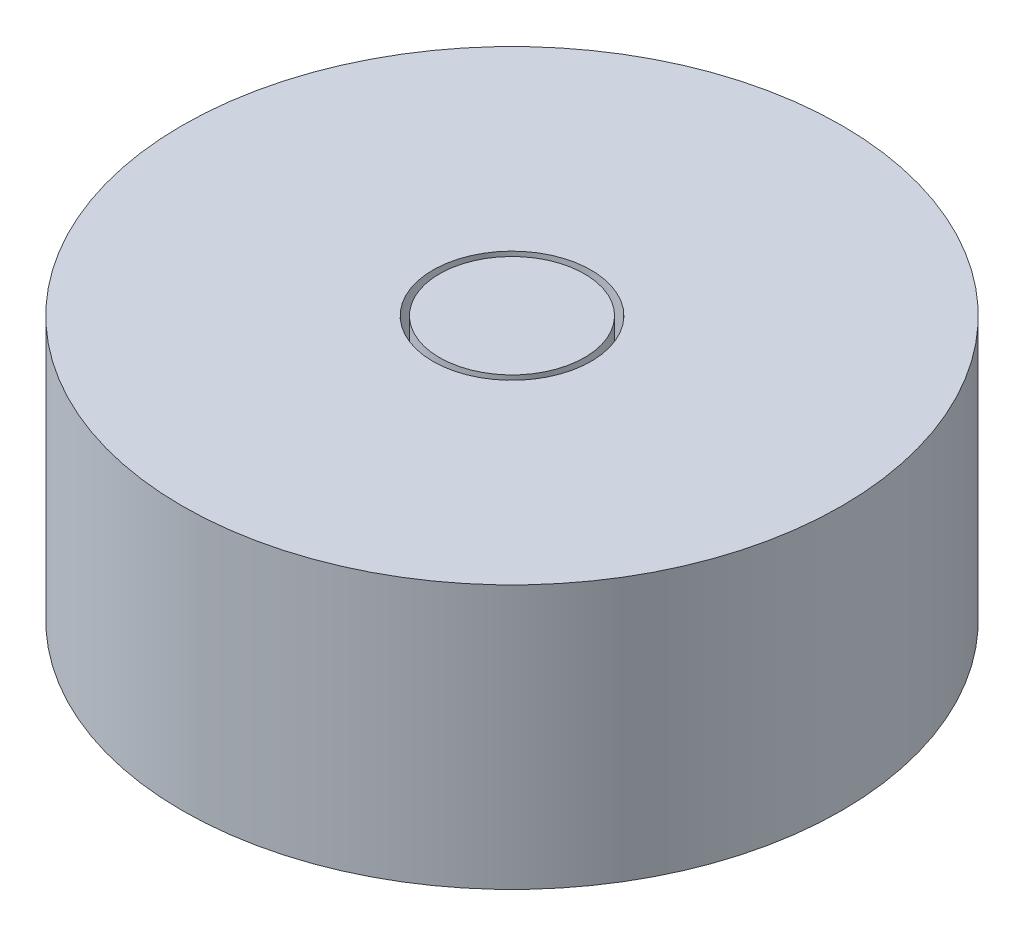
from build123d import *

# Parameters (mm, degrees)
SKETCH1_R      = 6.25
EXTRUDE1_DEPTH = 5
SKETCH2_R      = 1.5
SKETCH2_R_2    = 1.375
EXTRUDE2_DEPTH = 1


with BuildPart() as part:
    # Sketch1 → Extrude1 (new body)
    with BuildSketch(Plane(origin=(0, 0, 0), x_dir=(1, 0, 0), z_dir=(0, 1, 0))):
        with Locations(Location((0, 0, 0), (0, 0, 270))):  # turned: the seam where the file's is
            Circle(SKETCH1_R)
    extrude(amount=EXTRUDE1_DEPTH)

    # Sketch2 → Extrude2 (cut)
    with BuildSketch(Plane(origin=(0, 5, 0), x_dir=(1, 0, 0), z_dir=(0, 1, 0))):
        with Locations(Location((0, 0, 0), (0, 0, 270))):  # turned: the seam where the file's is
            Circle(SKETCH2_R)
        with Locations(Location((0, 0, 0), (0, 0, 270))):  # turned: the seam where the file's is
            Circle(SKETCH2_R_2, mode=Mode.SUBTRACT)
    extrude(amount=-EXTRUDE2_DEPTH, mode=Mode.SUBTRACT)


solid = part.part
